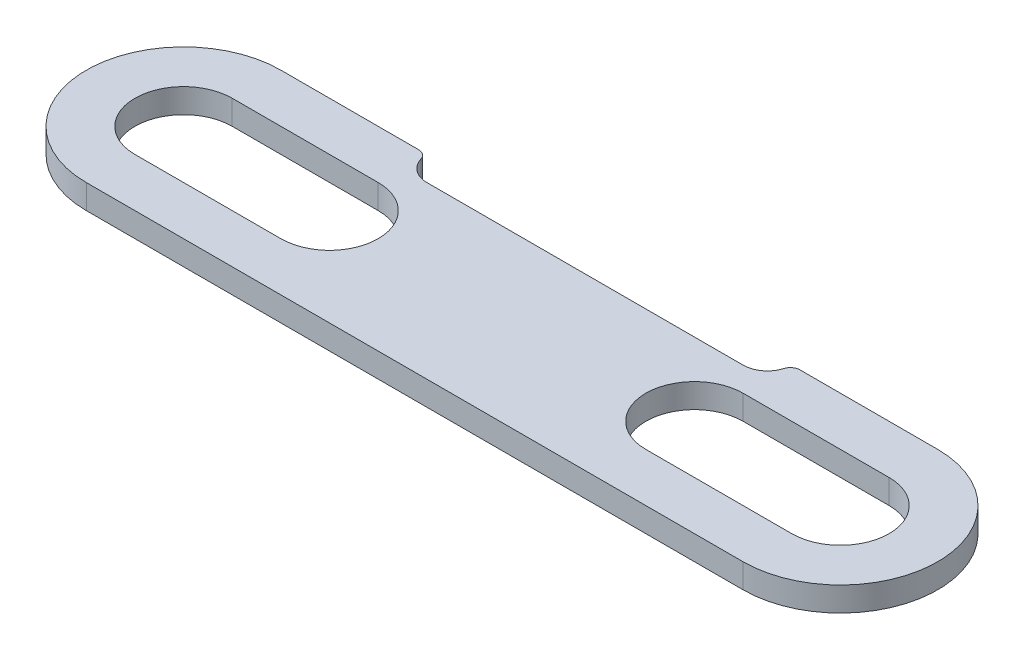
from build123d import *

# Parameters (mm, degrees)
BOSS_EXTRUDE1_DEPTH = 3.175
CUT_EXTRUDE1_DEPTH  = 7.35
FILLET1_R           = 2.54


with BuildPart() as part:
    # Sketch1 → Boss-Extrude1 (new body, symmetric)
    with BuildSketch(Plane(origin=(0, 0, 0), x_dir=(1, 0, 0), z_dir=(0, 1, 0))):
        with BuildLine():
            Line((-85.725, 25.4), (85.725, 25.4))
            ThreePointArc((85.725, 25.4), (111.125, 0), (85.725, -25.4))
            Line((85.725, -25.4), (-85.725, -25.4))
            ThreePointArc((-85.725, -25.4), (-111.125, 0), (-85.725, 25.4))
        make_face()
        with BuildLine():
            Line((-85.725, 12.7), (-47.625, 12.7))
            ThreePointArc((-47.625, 12.7), (-34.925, 0), (-47.625, -12.7))
            Line((-47.625, -12.7), (-85.725, -12.7))
            ThreePointArc((-85.725, -12.7), (-98.425, 0), (-85.725, 12.7))
        make_face(mode=Mode.SUBTRACT)
        with BuildLine():
            Line((85.725, 12.7), (47.625, 12.7))
            ThreePointArc((47.625, 12.7), (34.925, 0), (47.625, -12.7))
            Line((47.625, -12.7), (85.725, -12.7))
            ThreePointArc((85.725, -12.7), (98.425, 0), (85.725, 12.7))
        make_face(mode=Mode.SUBTRACT)
    extrude(amount=BOSS_EXTRUDE1_DEPTH, both=True)

    # Sketch2 → Cut-Extrude1 (cut, through all)
    with BuildSketch(Plane(origin=(0, 3.175, 0), x_dir=(1, 0, 0), z_dir=(0, 1, 0))):
        with BuildLine():
            Line((-41.275, 19.05), (41.275, 19.05))
            ThreePointArc((41.275, 19.05), (45.765128061, 20.909871939), (47.625, 25.4))
            Line((47.625, 25.4), (-47.625, 25.4))
            ThreePointArc((-47.625, 25.4), (-45.765128061, 20.909871939), (-41.275, 19.05))
        make_face()
    extrude(amount=-CUT_EXTRUDE1_DEPTH, mode=Mode.SUBTRACT)

    # Fillet1
    fillet1_edges = [part.edges().sort_by_distance(p)[0] for p in [
        (-47.625, 0, -25.4),
        (47.625, 0, -25.4),
    ]]
    fillet(fillet1_edges, radius=FILLET1_R)


solid = part.part
